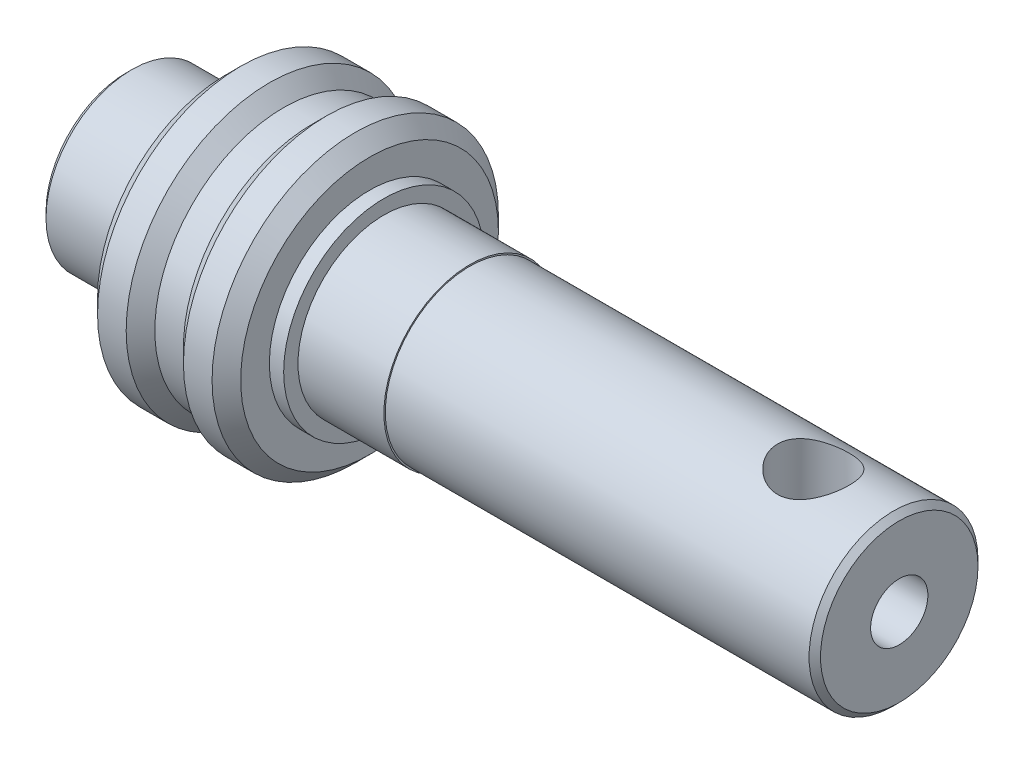
from build123d import *

# Parameters (mm, degrees)
FASE1_SIZE               = 0.5
M3_GEWINDEBOHRUNG1_D     = 2.5
M3_GEWINDEBOHRUNG1_DEPTH = 3
M3_GEWINDEBOHRUNG1_TIP   = 0.751075774
FASE2_SIZE               = 0.2


with BuildPart() as part:
    # Skizze1 → Rotation1 (revolve)
    with BuildSketch(Plane.XY):
        Polygon((-3, 3), (-6, 3), (-6, 0), (11, 0), (11, 1), (21, 1), (21, 2.95), (6, 2.95), (6, 3), (3, 3), (3, 3.5), (2.5, 3.5), (2.5, 5), (1, 5), (0.5, 4.5), (-0.5, 4.5), (-1, 5), (-2.5, 5), (-2.5, 3.5), (-3, 3.5), align=None)
    revolve(axis=Axis((-5.518776228, 0, 0), (-1, 0, 0)))

    # Fase1
    fase1_edges = [part.edges().sort_by_distance(p)[0] for p in [
        (2.5, -5, 0),
        (-2.5, -5, 0),
    ]]
    chamfer(fase1_edges, length=FASE1_SIZE)

    # M3 Gewindebohrung1
    with Locations(Plane(origin=(18, 3, 0), x_dir=(0, 0, 1), z_dir=(0, 1, 0))):
        with Locations((0, 0)):
            Hole(M3_GEWINDEBOHRUNG1_D / 2, depth=M3_GEWINDEBOHRUNG1_DEPTH)
            with Locations((0, 0, -(M3_GEWINDEBOHRUNG1_DEPTH + M3_GEWINDEBOHRUNG1_TIP / 2))):  # 118° drill point
                Cone(0, M3_GEWINDEBOHRUNG1_D / 2, M3_GEWINDEBOHRUNG1_TIP, mode=Mode.SUBTRACT)

    # Fase2
    fase2_edges = [part.edges().sort_by_distance(p)[0] for p in [
        (-6, -3, 0),
        (21, -2.95, 0),
    ]]
    chamfer(fase2_edges, length=FASE2_SIZE)


solid = part.part
